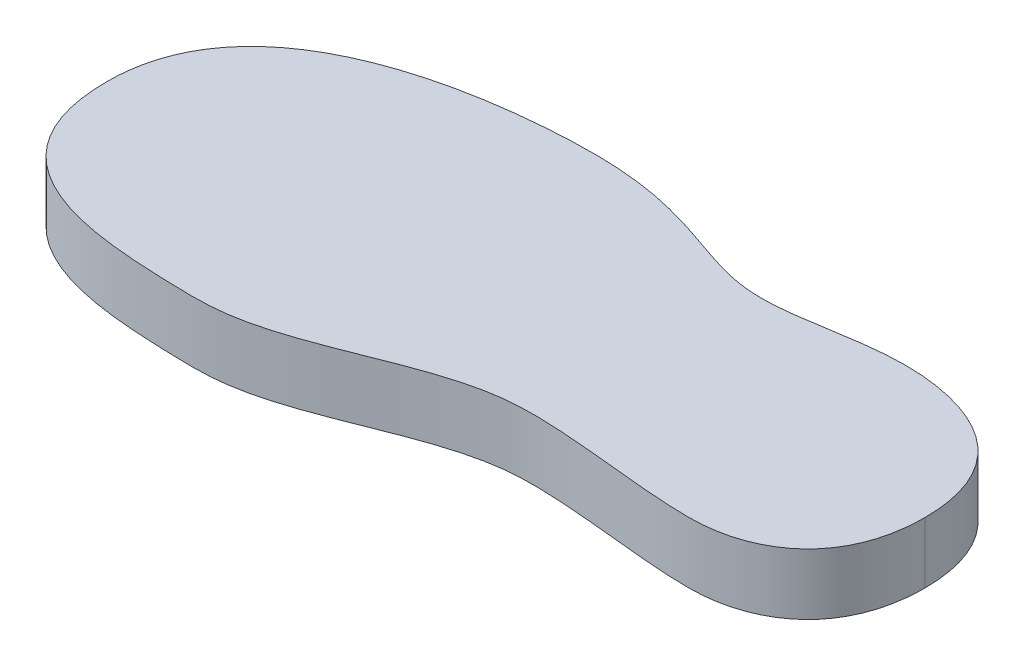
from build123d import *

# Parameters (mm, degrees)
BOSS_EXTRUDE1_DEPTH = 10


with BuildPart() as part:
    # Sketch2 → Boss-Extrude1 (new body)
    with BuildSketch(Plane(origin=(0, 0, 0), x_dir=(1, 0, 0), z_dir=(0, 1, 0))):
        with BuildLine():
            add(Edge.make_bspline(
                [(-109.1, -5.1), (-109.1, 18.310560024), (-73.80935943, 24.695842218), (-43.000886004, 24.407374037), (-34.220034869, 17.83884646), (-19.74517309, 17.562611296), (-9.831482581, 20.089121647), (7.173622502, 19.93578541), (19.6, 14.289300505), (19.6, 0)],
                knots=[0, 0, 0, 0, 0.230584101, 0.286176341, 0.525950611, 0.574149071, 0.719962477, 0.764370237, 1, 1, 1, 1], degree=3))
            add(Edge.make_bspline(
                [(19.6, 0), (19.6, -12.798208112), (9.628339195, -19.558649887), (-8.537408911, -19.135204318), (-19.796385689, -17.357223298), (-41.21861702, -17.372886462), (-58.113965099, -28.979482333), (-85.155395015, -28.327654779), (-109.1, -26.64326042), (-109.1, -5.1)],
                knots=[0, 0, 0, 0, 0.174620331, 0.213184502, 0.3664798, 0.418282358, 0.679407529, 0.740843358, 1, 1, 1, 1], degree=3))
        make_face()
    extrude(amount=BOSS_EXTRUDE1_DEPTH)


solid = part.part
